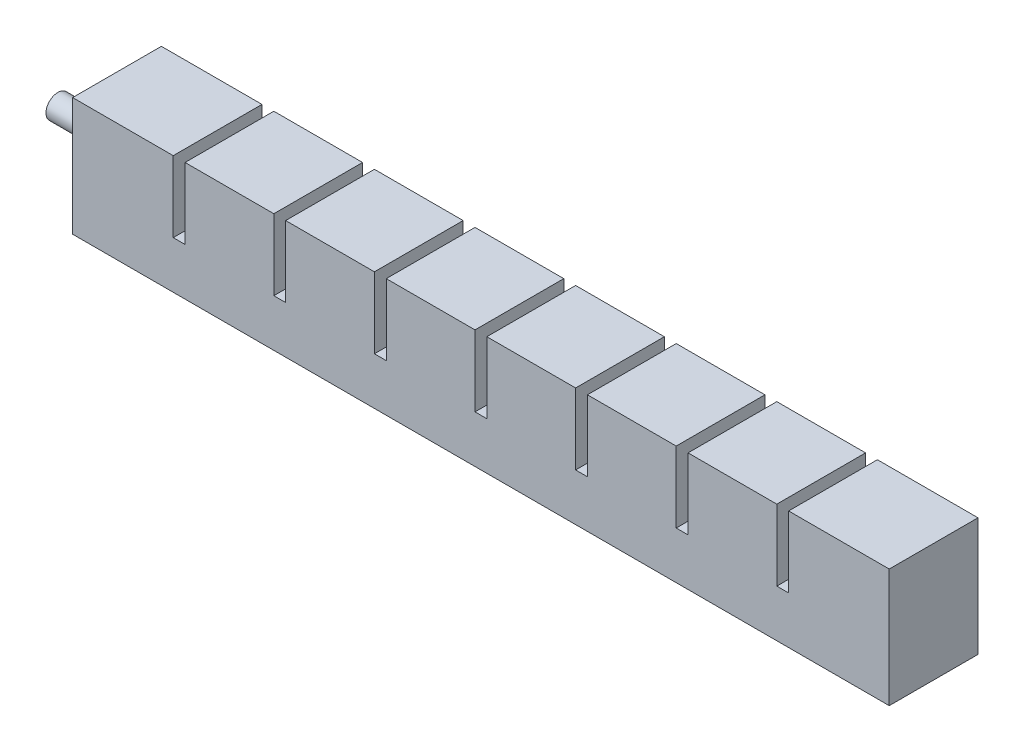
from build123d import *

# Parameters (mm, degrees)
SKETCH1_W           = 15
SKETCH1_H           = 15
BOSS_EXTRUDE1_DEPTH = 15
SKETCH2_W           = 7
SKETCH2_H           = 7
CUT_EXTRUDE1_DEPTH  = 11
SKETCH3_W           = 15
SKETCH3_H           = 3
BOSS_EXTRUDE2_DEPTH = 2
LPATTERN1_COUNT     = 8
LPATTERN1_PITCH     = 17
SKETCH9_W           = 15
SKETCH9_H           = 12
BOSS_EXTRUDE3_DEPTH = 2
SKETCH10_W          = 15
SKETCH10_H          = 15
BOSS_EXTRUDE4_DEPTH = 2
SKETCH11_W          = 112
SKETCH11_H          = 2.5
CUT_EXTRUDE2_DEPTH  = 2
SKETCH12_W          = 138
SKETCH12_H          = 15
BOSS_EXTRUDE5_DEPTH = 3
SKETCH13_W          = 138
SKETCH13_H          = 15
BOSS_EXTRUDE6_DEPTH = 2
SKETCH14_R          = 2
BOSS_EXTRUDE7_DEPTH = 10
SKETCH15_R          = 1
CUT_EXTRUDE3_DEPTH  = 18


with BuildPart() as part:
    # Sketch1 → Boss-Extrude1 (new body)
    with BuildSketch(Plane.XY):
        with Locations((7.5, 7.5)):
            Rectangle(SKETCH1_W, SKETCH1_H)
    extrude(amount=BOSS_EXTRUDE1_DEPTH)

    # Sketch2 → Cut-Extrude1 (cut)
    with BuildSketch(Plane.XZ):
        with Locations((7.5, 7.5)):
            Rectangle(SKETCH2_W, SKETCH2_H)
    extrude(amount=-CUT_EXTRUDE1_DEPTH, mode=Mode.SUBTRACT)

    # Sketch3 → Boss-Extrude2 (add)
    with BuildSketch(Plane(origin=(15, 0, 0), x_dir=(0, 0, -1), z_dir=(1, 0, 0))):
        with Locations((-7.5, 1.5)):
            Rectangle(SKETCH3_W, SKETCH3_H)
    extrude(amount=BOSS_EXTRUDE2_DEPTH)


with BuildPart() as lpattern1_1:
    # LPattern1: pattern copy
    add(part.part.moved(Location(Vector(1, 0, 0) * (1 * LPATTERN1_PITCH))))


with BuildPart() as lpattern1_2:
    # LPattern1: pattern copy
    add(part.part.moved(Location(Vector(1, 0, 0) * (2 * LPATTERN1_PITCH))))


with BuildPart() as lpattern1_3:
    # LPattern1: pattern copy
    add(part.part.moved(Location(Vector(1, 0, 0) * (3 * LPATTERN1_PITCH))))


with BuildPart() as lpattern1_4:
    # LPattern1: pattern copy
    add(part.part.moved(Location(Vector(1, 0, 0) * (4 * LPATTERN1_PITCH))))


with BuildPart() as lpattern1_5:
    # LPattern1: pattern copy
    add(part.part.moved(Location(Vector(1, 0, 0) * (5 * LPATTERN1_PITCH))))


with BuildPart() as lpattern1_6:
    # LPattern1: pattern copy
    add(part.part.moved(Location(Vector(1, 0, 0) * (6 * LPATTERN1_PITCH))))


with BuildPart() as lpattern1_7:
    # LPattern1: pattern copy
    add(part.part.moved(Location(Vector(1, 0, 0) * (7 * LPATTERN1_PITCH))))


with BuildPart() as lpattern1_6_1:
    add(lpattern1_6.part)

    # Combine1: union LPattern1_7, LPattern1_1, LPattern1_2, LPattern1_3, LPattern1_4, part, LPattern1_5
    add(lpattern1_7.part)
    add(lpattern1_1.part)
    add(lpattern1_2.part)
    add(lpattern1_3.part)
    add(lpattern1_4.part)
    add(part.part)
    add(lpattern1_5.part)

    # Sketch9 → Boss-Extrude3 (add)
    with BuildSketch(Plane(origin=(134, 0, 0), x_dir=(0, 0, -1), z_dir=(1, 0, 0))):
        with Locations((-7.5, 9)):
            Rectangle(SKETCH9_W, SKETCH9_H)
    extrude(amount=BOSS_EXTRUDE3_DEPTH)

    # Sketch10 → Boss-Extrude4 (add)
    with BuildSketch(Plane.ZY):
        with Locations((7.5, 7.5)):
            Rectangle(SKETCH10_W, SKETCH10_H)
    extrude(amount=BOSS_EXTRUDE4_DEPTH)

    # Sketch11 → Cut-Extrude2 (cut)
    with BuildSketch(Plane.XZ):
        with Locations((67, 7.5)):
            Rectangle(SKETCH11_W, SKETCH11_H)
    extrude(amount=-CUT_EXTRUDE2_DEPTH, mode=Mode.SUBTRACT)

    # Sketch12 → Boss-Extrude5 (add)
    with BuildSketch(Plane.XZ):
        with Locations((67, 7.5)):
            Rectangle(SKETCH12_W, SKETCH12_H)
    extrude(amount=BOSS_EXTRUDE5_DEPTH)

    # Sketch13 → Boss-Extrude6 (add)
    with BuildSketch(Plane.XZ.offset(3)):
        with Locations((67, 7.5)):
            Rectangle(SKETCH13_W, SKETCH13_H)
    extrude(amount=BOSS_EXTRUDE6_DEPTH)

    # Sketch14 → Boss-Extrude7 (add)
    with BuildSketch(Plane.ZY.offset(2)):
        with Locations((7.5, 5)):
            Circle(SKETCH14_R)
    extrude(amount=BOSS_EXTRUDE7_DEPTH)

    # Sketch15 → Cut-Extrude3 (cut)
    with BuildSketch(Plane.ZY.offset(12)):
        with Locations((7.5, 5)):
            Circle(SKETCH15_R)
    extrude(amount=-CUT_EXTRUDE3_DEPTH, mode=Mode.SUBTRACT)


solid = lpattern1_6_1.part
